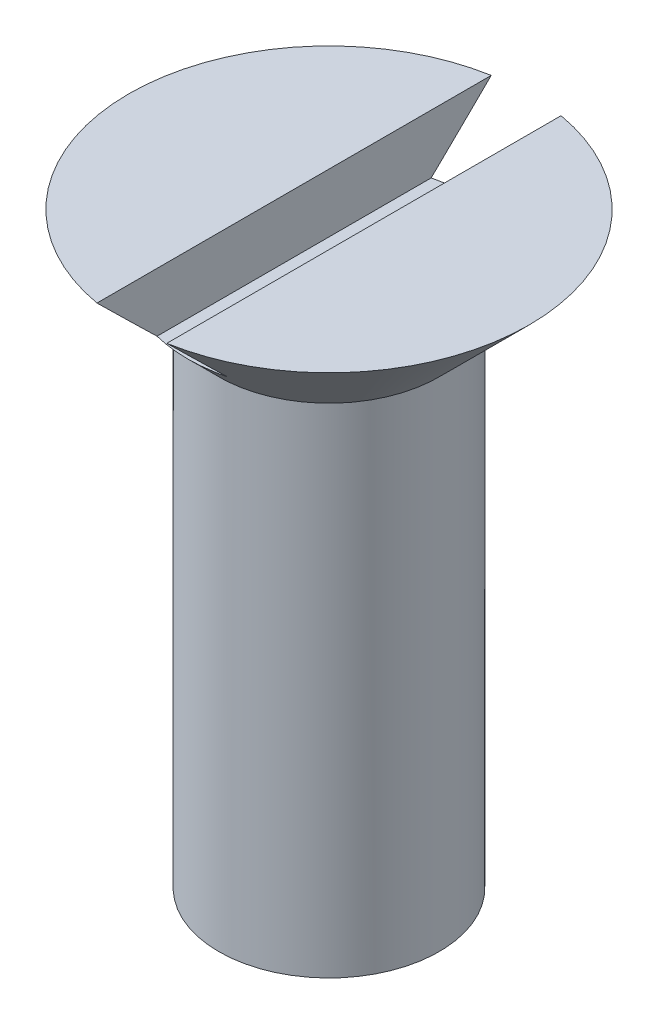
from build123d import *

# Parameters (mm, degrees)
SKETCH2_W               = 1.9
SKETCH2_H               = 1.6
CUT_EXTRUDE1_DEPTH      = 6.45
CUT_EXTRUDE1_DEPTH_BACK = 6.45


with BuildPart() as part:
    # Sketch1 → Revolve1 (revolve)
    with BuildSketch(Plane.XY):
        Polygon((0, 0), (0, 17.732050808), (5.45, 17.732050808), (3, 15.282050808), (3, 1.732050808), align=None)
    revolve(axis=Axis((0, 0, 0), (0, 1, 0)))

    # Sketch2 → Cut-Extrude1 (cut, two sides)
    with BuildSketch(Plane.XY) as cut_extrude1_sk:
        with Locations((0, 16.932050808)):
            Rectangle(SKETCH2_W, SKETCH2_H)
    extrude(amount=CUT_EXTRUDE1_DEPTH, mode=Mode.SUBTRACT)
    extrude(cut_extrude1_sk.sketch, amount=-CUT_EXTRUDE1_DEPTH_BACK, mode=Mode.SUBTRACT)


solid = part.part
